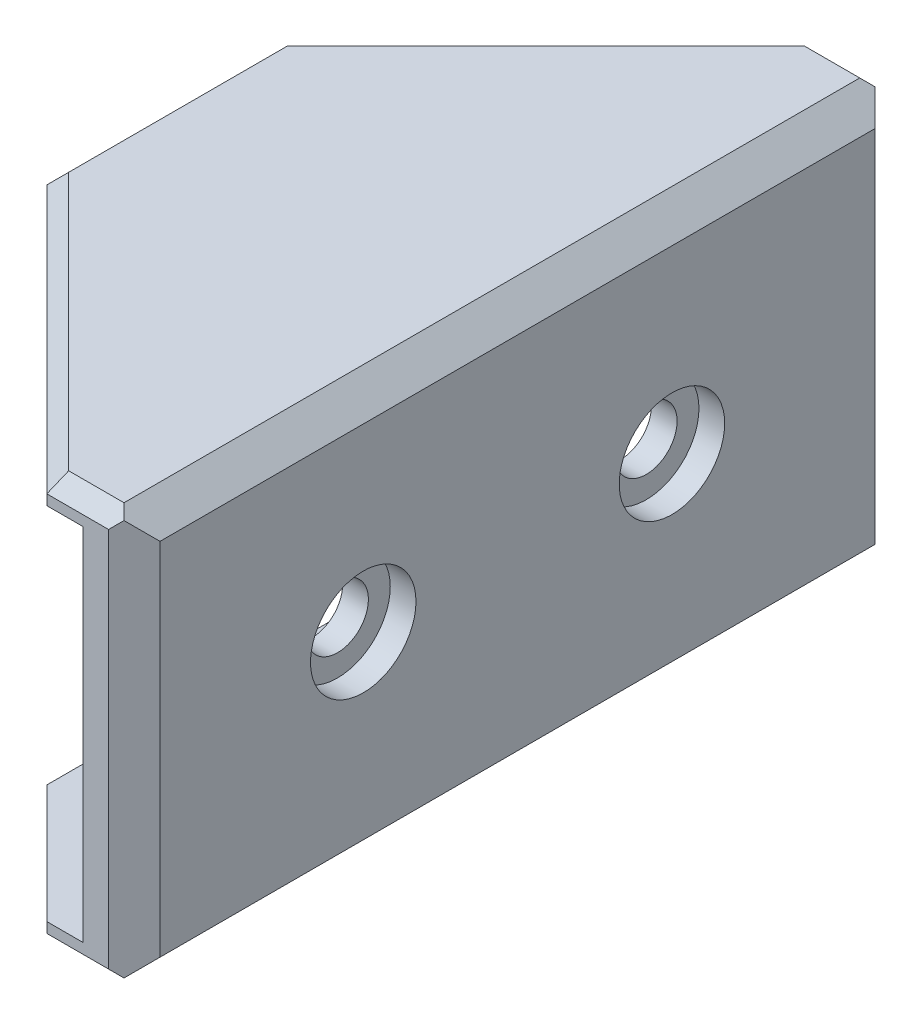
from build123d import *

# Parameters (mm, degrees)
EXTRUDE_1_DEPTH     = 16
CUT_EXTRUDE_START   = 1
CUT_EXTRUDE_1_DEPTH = 14
SKETCH_4_W          = 35.141232352
SKETCH_4_H          = 2.32880635
CUT_EXTRUDE_4_DEPTH = 5.8
CHAMFER_2_SIZE      = 1
CHAMFER_1_SIZE      = 0.6
CUT_EXTRUDE_2_REACH = 38.531
SKETCH_2_R          = 1.2
SKETCH_3_R          = 2.05
CUT_EXTRUDE_3_DEPTH = 1


with BuildPart() as part:
    # 草图1 → 凸台-拉伸1 (new body)
    with BuildSketch(Plane(origin=(0, 0, 0), x_dir=(1, 0, 0), z_dir=(0, 1, 0))):
        Polygon((-10.4, 10.4), (0, 0), (3.4, 0), (3.4, 29.8), (0, 29.8), (-10.4, 19.4), align=None)
    extrude(amount=EXTRUDE_1_DEPTH)

    # 草图1<3> → 切除-拉伸1 (cut)
    with BuildSketch(Plane(origin=(0, 0, 0), x_dir=(1, 0, 0), z_dir=(0, 1, 0)).offset(CUT_EXTRUDE_START)):
        Polygon((-10.4, 10.4), (0, 0), (1.4, 0), (1.4, 29.8), (0, 29.8), (-10.4, 19.4), align=None)
    extrude(amount=CUT_EXTRUDE_1_DEPTH, mode=Mode.SUBTRACT)

    # 草图4 → 切除-拉伸4 (cut)
    with BuildSketch(Plane.ZY.offset(10.4)):
        with Locations((-15.55462397, -0.164403175)):
            Rectangle(SKETCH_4_W, SKETCH_4_H)
    extrude(amount=-CUT_EXTRUDE_4_DEPTH, mode=Mode.SUBTRACT)

    # 倒角2
    chamfer_2_edges = [part.edges().sort_by_distance(p)[0] for p in [
        (3.4, 8, -29.8),
        (3.4, 8, 0),
        (3.4, 16, -14.9),
        (3.4, 0, -14.9),
    ]]
    chamfer(chamfer_2_edges, length=CHAMFER_2_SIZE)

    # 倒角1
    chamfer_1_edges = [part.edges().sort_by_distance(p)[0] for p in [
        (1.2, 0, -29.8),
        (1.2, 0, 0),
        (-2.3, 0, -2.3),
        (-2.3, 0, -27.5),
        (1.2, 16, -29.8),
        (1.2, 16, 0),
        (-5.2, 16, -24.6),
        (-5.2, 16, -5.2),
        (-10.4, 16, -14.9),
        (-4.6, 0, -14.9),
    ]]
    chamfer(chamfer_1_edges, length=CHAMFER_1_SIZE)

    # 草图2 → 切除-拉伸2 (cut, up to next)
    with BuildSketch(Plane(origin=(3.4, 0, 0), x_dir=(0, 0, -1), z_dir=(1, 0, 0)), mode=Mode.PRIVATE) as cut_extrude_2_sk1:
        with Locations((8.9, 8)):
            Circle(SKETCH_2_R)
    cut_extrude_2_tool1 = extrude(cut_extrude_2_sk1.sketch, amount=-CUT_EXTRUDE_2_REACH, mode=Mode.PRIVATE) & part.part
    # 草图2 → 切除-拉伸2 (cut, up to next)
    with BuildSketch(Plane(origin=(3.4, 0, 0), x_dir=(0, 0, -1), z_dir=(1, 0, 0)), mode=Mode.PRIVATE) as cut_extrude_2_sk2:
        with Locations((20.9, 8)):
            Circle(SKETCH_2_R)
    cut_extrude_2_tool2 = extrude(cut_extrude_2_sk2.sketch, amount=-CUT_EXTRUDE_2_REACH, mode=Mode.PRIVATE) & part.part
    add(cut_extrude_2_tool1.solids().sort_by_distance((3.4, 8, -8.9))[0], mode=Mode.SUBTRACT)
    add(cut_extrude_2_tool2.solids().sort_by_distance((3.4, 8, -20.9))[0], mode=Mode.SUBTRACT)

    # 草图3 → 切除-拉伸3 (cut)
    with BuildSketch(Plane(origin=(3.4, 0, 0), x_dir=(0, 0, -1), z_dir=(1, 0, 0))):
        with Locations((8.9, 8)):
            Circle(SKETCH_3_R)
        with Locations((20.9, 8)):
            Circle(SKETCH_3_R)
    extrude(amount=-CUT_EXTRUDE_3_DEPTH, mode=Mode.SUBTRACT)


solid = part.part
